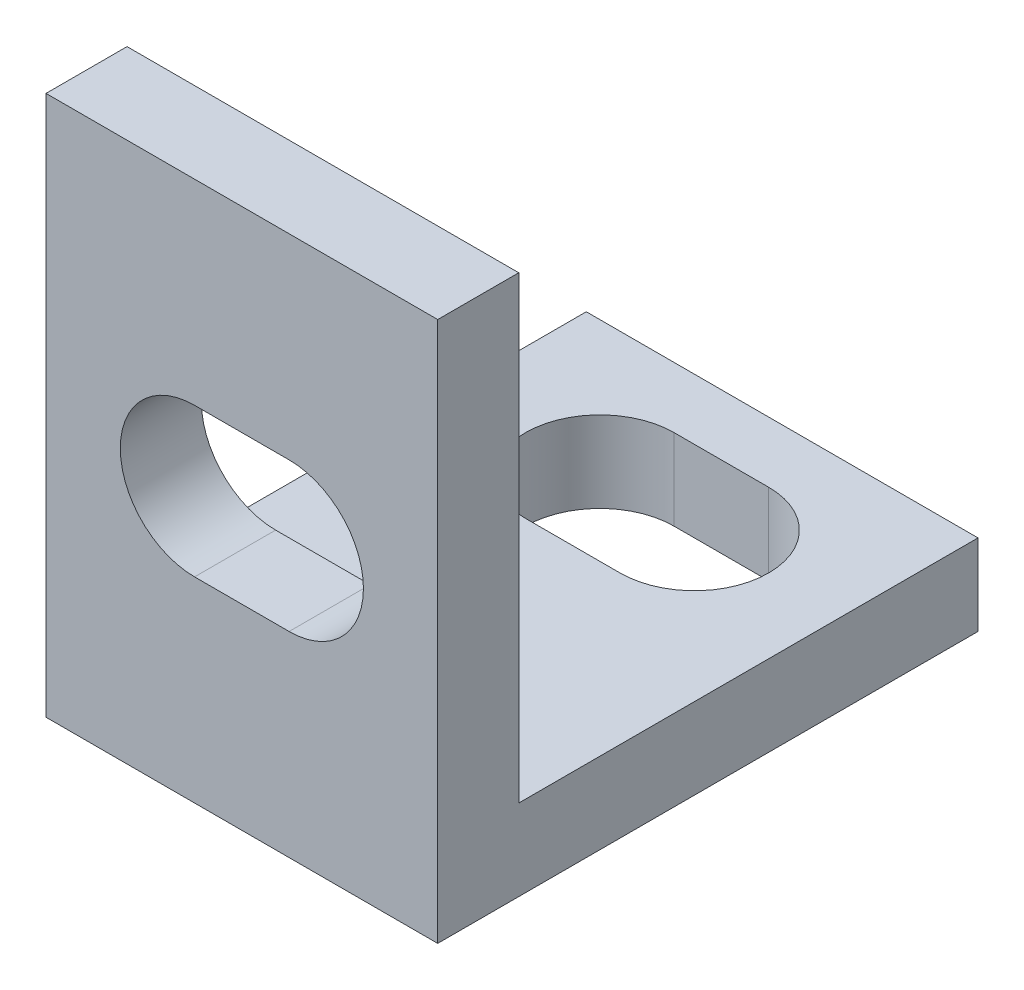
from build123d import *

# Parameters (mm, degrees)
BOSS_EXTRUDE1_DEPTH = 14.5
CUT_EXTRUDE1_DEPTH  = 4
CUT_EXTRUDE2_DEPTH  = 4


with BuildPart() as part:
    # Sketch1 → Boss-Extrude1 (new body)
    with BuildSketch(Plane(origin=(0, 0, 0), x_dir=(0, 0, -1), z_dir=(1, 0, 0))):
        Polygon((0, 20), (0, 0), (20, 0), (20, 3), (3, 3), (3, 20), align=None)
    extrude(amount=-BOSS_EXTRUDE1_DEPTH)

    # Sketch2 → Cut-Extrude1 (cut, through all)
    with BuildSketch(Plane(origin=(0, 0, -3), x_dir=(-1, 0, 0), z_dir=(0, 0, -1))):
        with BuildLine():
            Line((5.5, 12.75), (9, 12.75))
            ThreePointArc((9, 12.75), (11.75, 10), (9, 7.25))
            Line((9, 7.25), (5.5, 7.25))
            ThreePointArc((5.5, 7.25), (2.75, 10), (5.5, 12.75))
        make_face()
    extrude(amount=-CUT_EXTRUDE1_DEPTH, mode=Mode.SUBTRACT)

    # Sketch3 → Cut-Extrude2 (cut, through all)
    with BuildSketch(Plane(origin=(0, 3, 0), x_dir=(1, 0, 0), z_dir=(0, 1, 0))):
        with BuildLine():
            Line((-5.5, 12.25), (-9, 12.25))
            ThreePointArc((-9, 12.25), (-11.75, 15), (-9, 17.75))
            Line((-9, 17.75), (-5.5, 17.75))
            ThreePointArc((-5.5, 17.75), (-2.75, 15), (-5.5, 12.25))
        make_face()
    extrude(amount=-CUT_EXTRUDE2_DEPTH, mode=Mode.SUBTRACT)


solid = part.part
